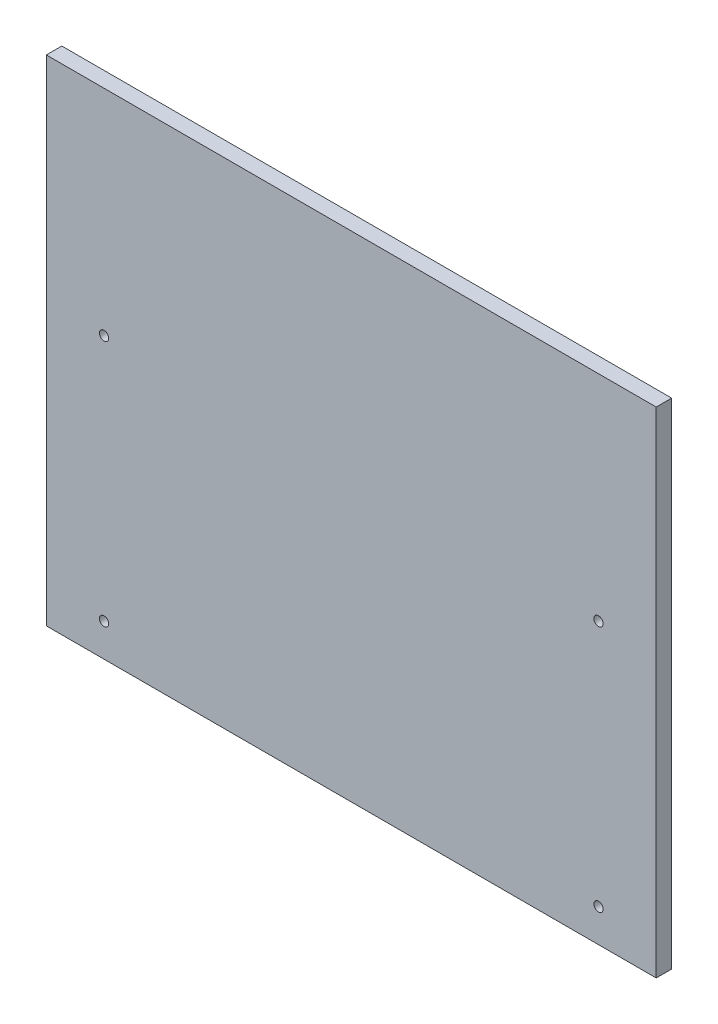
from build123d import *

# Parameters (mm, degrees)
SKETCH1_W                       = 469.9
SKETCH1_H                       = 381
BOSS_EXTRUDE1_DEPTH             = 11.90625
F_9_32_0_28125_DIAMETER_HOLE1_D = 7.14375


with BuildPart() as part:
    # Sketch1 → Boss-Extrude1 (new body)
    with BuildSketch(Plane.XY):
        Rectangle(SKETCH1_W, SKETCH1_H)
    extrude(amount=BOSS_EXTRUDE1_DEPTH)

    # 9/32 (0.28125) Diameter Hole1 (through all)
    with Locations(Plane(origin=(-190.5, 25.4, 11.90625), x_dir=(1, 0, 0), z_dir=(0, 0, 1))):
        with Locations((0, 0), (381, 0), (381, -190.5), (0, -190.5)):
            Hole(F_9_32_0_28125_DIAMETER_HOLE1_D / 2)


solid = part.part
